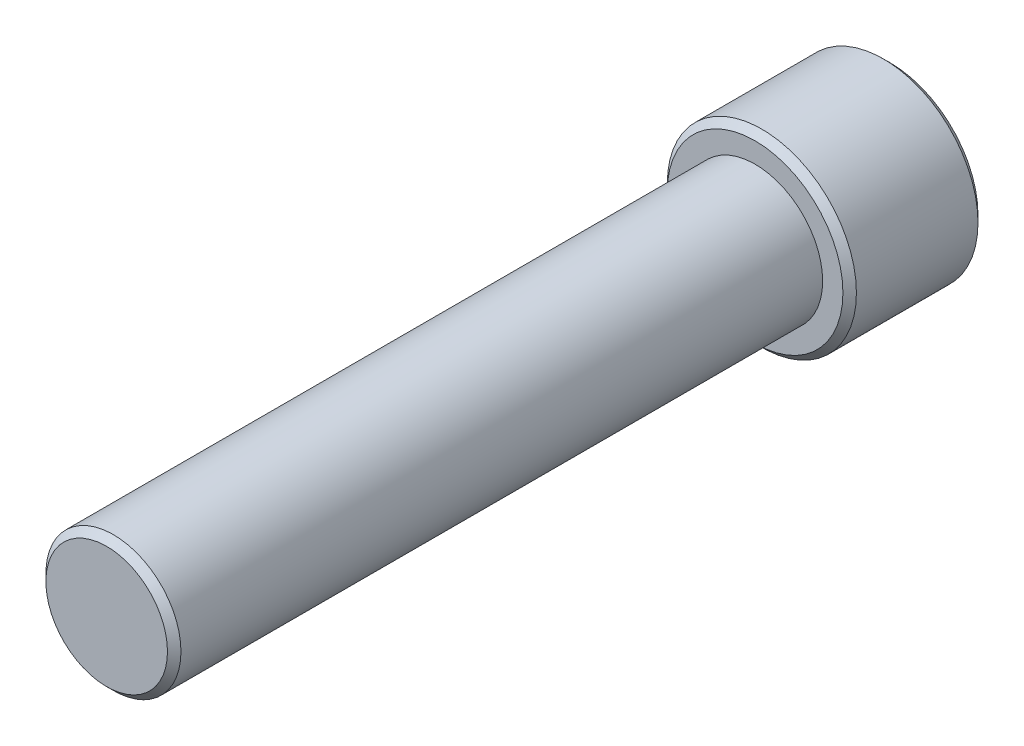
from build123d import *

# Parameters (mm, degrees)
SCHIZZO1_R                   = 3.5
ESTRUSIONE_ESTRUSIONE1_DEPTH = 5
SCHIZZO2_R                   = 2.5
ESTRUSIONE_ESTRUSIONE2_DEPTH = 24
SMUSSO1_SIZE                 = 0.25


with BuildPart() as part:
    # Schizzo1 → Estrusione-Estrusione1 (new body)
    with BuildSketch(Plane.XY):
        Circle(SCHIZZO1_R)
    extrude(amount=ESTRUSIONE_ESTRUSIONE1_DEPTH)

    # Schizzo2 → Estrusione-Estrusione2 (add)
    with BuildSketch(Plane.XY.offset(5)):
        Circle(SCHIZZO2_R)
    extrude(amount=ESTRUSIONE_ESTRUSIONE2_DEPTH)

    # Smusso1
    smusso1_edges = [part.edges().sort_by_distance(p)[0] for p in [
        (-3.5, 0, 0),
        (-3.5, 0, 5),
        (-2.5, 0, 29),
    ]]
    chamfer(smusso1_edges, length=SMUSSO1_SIZE)


solid = part.part
